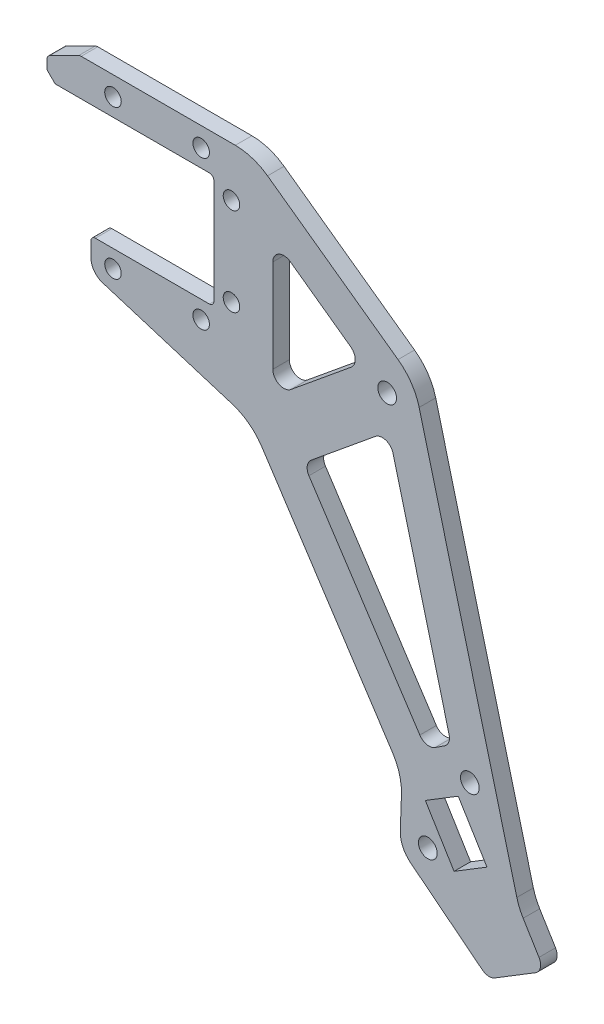
from build123d import *

# Parameters (mm, degrees)
BOSS_EXTRU_1_DEPTH      = 3
D_GAGEMENT_M21_D        = 3
CHANFREIN1_SIZE         = 1.5
CHANFREIN2_SIZE         = 6
CHANFREIN2_SIZE2        = 3
CONG_1_R                = 2
CONG_2_R                = 10
CONG_2_2_R              = 5
CONG_3_R                = 0.8
D_GAGEMENT_M31_D        = 3.4
ENL_V_MAT_EXTRU_1_REACH = 5
FILLET_1_R              = 3
FILLET_2_R              = 1
SKETCH_5_R              = 1.5
CUT_EXTRUDE_2_DEPTH     = 3
SKETCH_6_R              = 1.5
EXTRUDE_3_DEPTH         = 3


with BuildPart() as part:
    # Esquisse1 → Boss.-Extru.1 (new body)
    with BuildSketch(Plane.XY):
        Polygon((48.900602827, -4.024), (19.677471167, 17), (-17.75, 17), (-17.75, 10.3), (12.55, 10.3), (12.55, -10.3), (-9.75, -10.3), (-9.75, -16), (19.295179393, -24.993298238), (46.71123265, -66.806693506), (46.285412403, -78.306693506), (62.357629227, -91.032016541), (72.595795313, -84.772627178), (67.901253291, -77.094002614), align=None)
        Polygon((28.816069815, -26.747772307), (44.278044238, -14.062058021), (55.602935243, -57.613715208), (51.023072953, -60.616622474), align=None, mode=Mode.SUBTRACT)
        Polygon((23.25, -19.026221012), (23.25, 5.973778988), (39.485073144, -5.706221012), align=None, mode=Mode.SUBTRACT)
    extrude(amount=BOSS_EXTRU_1_DEPTH)

    # D_gagement M21 (through all)
    with Locations(Plane.XY.offset(3)):
        with Locations((-13.75, 13.5), (-5.75, 13.5), (2.25, 13.5), (10.25, 13.5), (15.75, 8), (15.75, -8), (10.25, -13.5)):
            Hole(D_GAGEMENT_M21_D / 2)

    # Chanfrein1
    chanfrein1_edges = [part.edges().sort_by_distance(p)[0] for p in [
        (-17.75, 10.3, 1.5),
    ]]
    chamfer(chanfrein1_edges, length=CHANFREIN1_SIZE)

    # Chanfrein2
    chanfrein2_edges = [part.edges().sort_by_distance(p)[0] for p in [
        (-17.75, 17, 1.5),
    ]]
    chanfrein2_side = [part.faces().sort_by_distance(p)[0] for p in [
        (0.963735584, 17, 1.5),
    ]]
    chamfer(chanfrein2_edges, length=CHANFREIN2_SIZE, length2=CHANFREIN2_SIZE2, reference=chanfrein2_side[0])

    # Cong_1
    cong_1_edges = [part.edges().sort_by_distance(p)[0] for p in [
        (72.595795313, -84.772627178, 1.5),
        (62.357629227, -91.032016541, 1.5),
        (23.25, 5.973778988, 1.5),
        (23.25, -19.026221012, 1.5),
        (39.485073144, -5.706221012, 1.5),
        (51.023072953, -60.616622474, 1.5),
        (55.602935243, -57.613715208, 1.5),
        (44.278044238, -14.062058021, 1.5),
        (28.816069815, -26.747772307, 1.5),
    ]]
    fillet(cong_1_edges, radius=CONG_1_R)

    # Cong_2
    cong_2_edges = [part.edges().sort_by_distance(p)[0] for p in [
        (19.677471167, 17, 1.5),
        (48.900602827, -4.024, 1.5),
        (19.295179393, -24.993298238, 1.5),
        (46.71123265, -66.806693506, 1.5),
        (67.901253291, -77.094002614, 1.5),
    ]]
    fillet(cong_2_edges, radius=CONG_2_R)

    # Cong_2 2
    cong_2_2_edges = [part.edges().sort_by_distance(p)[0] for p in [
        (46.285412403, -78.306693506, 1.5),
    ]]
    fillet(cong_2_2_edges, radius=CONG_2_2_R)

    # Cong_3
    cong_3_edges = [part.edges().sort_by_distance(p)[0] for p in [
        (-9.75, -10.3, 1.5),
        (12.55, -10.3, 1.5),
        (12.55, 10.3, 1.5),
    ]]
    fillet(cong_3_edges, radius=CONG_3_R)

    # D_gagement M31 (through all)
    with Locations(Plane(origin=(0, 0, 0), x_dir=(-1, 0, 0), z_dir=(0, 0, -1))):
        with Locations((-44, -8.146072926), (-59, -61.892892977), (-51.375748619, -75.959548261)):
            Hole(D_GAGEMENT_M31_D / 2)

    # Esquisse6 → Enl_v. mat.-Extru.1 (cut, up to next)
    with BuildSketch(Plane.XY.offset(3), mode=Mode.PRIVATE) as enl_v_mat_extru_1_sk1:
        Polygon((50.923621455, -68.720394376), (56.895885005, -65.069083914), (62.112042808, -73.600888985), (56.139779258, -77.252199447), align=None)
    enl_v_mat_extru_1_tool1 = extrude(enl_v_mat_extru_1_sk1.sketch, amount=-ENL_V_MAT_EXTRU_1_REACH, mode=Mode.PRIVATE) & part.part
    add(enl_v_mat_extru_1_tool1.solids().sort_by_distance((56.517832, -71.160642, 3))[0], mode=Mode.SUBTRACT)

    # Fillet 1
    fillet_1_edges = [part.edges().sort_by_distance(p)[0] for p in [
        (-9.75, -16, 1.5),
    ]]
    fillet(fillet_1_edges, radius=FILLET_1_R)

    # Fillet 2
    fillet_2_edges = [part.edges().sort_by_distance(p)[0] for p in [
        (-17.75, 14, 1.5),
        (-11.75, 17, 1.5),
    ]]
    fillet(fillet_2_edges, radius=FILLET_2_R)

    # Sketch 5 → Cut-Extrude 2 (cut)
    with BuildSketch(Plane(origin=(0, 0, 0), x_dir=(-1, 0, 0), z_dir=(0, 0, -1))):
        with Locations((5.75, -13.5)):
            Circle(SKETCH_5_R)
    extrude(amount=-CUT_EXTRUDE_2_DEPTH, mode=Mode.SUBTRACT)

    # Sketch 6 → Extrude 3 (add)
    with BuildSketch(Plane(origin=(0, 0, 0), x_dir=(-1, 0, 0), z_dir=(0, 0, -1))):
        with Locations((13.75, 13.5)):
            Circle(SKETCH_6_R)
        with Locations((-2.25, 13.5)):
            Circle(SKETCH_6_R)
    extrude(amount=-EXTRUDE_3_DEPTH)


solid = part.part
